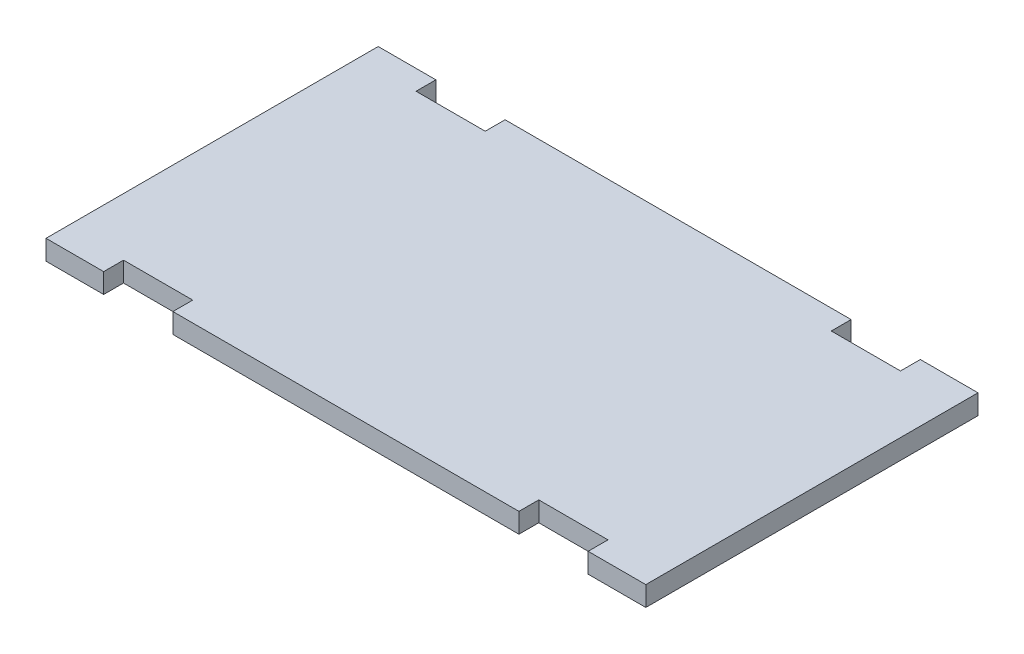
from build123d import *

# Parameters (mm, degrees)
SKETCH1_W           = 165.1
SKETCH1_H           = 91.44
BOSS_EXTRUDE1_DEPTH = 5.461
SKETCH2_W           = 19.05
SKETCH2_H           = 5.461
CUT_EXTRUDE1_DEPTH  = 6.461
BOSS_EXTRUDE2_DEPTH = 5.461


with BuildPart() as part:
    # Sketch1 → Boss-Extrude1 (new body)
    with BuildSketch(Plane(origin=(0, 0, 0), x_dir=(1, 0, 0), z_dir=(0, 1, 0))):
        with Locations((0, -0.259)):
            Rectangle(SKETCH1_W, SKETCH1_H)
        with BuildLine():
            Line((-47.5, 40), (47.5, 40))
            ThreePointArc((47.5, 40), (52.803300859, 37.803300859), (55, 32.5))
            Line((55, 32.5), (55, -32.5))
            ThreePointArc((55, -32.5), (52.803300859, -37.803300859), (47.5, -40))
            Line((47.5, -40), (-47.5, -40))
            ThreePointArc((-47.5, -40), (-52.803300859, -37.803300859), (-55, -32.5))
            Line((-55, -32.5), (-55, 32.5))
            ThreePointArc((-55, 32.5), (-52.803300859, 37.803300859), (-47.5, 40))
        make_face(mode=Mode.SUBTRACT)
    extrude(amount=BOSS_EXTRUDE1_DEPTH)

    # Sketch2 → Cut-Extrude1 (cut, through all)
    with BuildSketch(Plane(origin=(0, 5.461, 0), x_dir=(1, 0, 0), z_dir=(0, 1, 0))):
        with Locations((-57.15, 42.7305)):
            Rectangle(SKETCH2_W, SKETCH2_H)
        with Locations((-57.15, -43.2485)):
            Rectangle(SKETCH2_W, SKETCH2_H)
        with Locations((57.15, -43.2485)):
            Rectangle(SKETCH2_W, SKETCH2_H)
        with Locations((57.15, 42.7305)):
            Rectangle(SKETCH2_W, SKETCH2_H)
    extrude(amount=-CUT_EXTRUDE1_DEPTH, mode=Mode.SUBTRACT)

    # Sketch1_3 → Boss-Extrude2 (add)
    with BuildSketch(Plane(origin=(0, 0, 0), x_dir=(1, 0, 0), z_dir=(0, 1, 0))):
        with BuildLine():
            Line((-47.5, 40), (47.5, 40))
            ThreePointArc((47.5, 40), (52.803300859, 37.803300859), (55, 32.5))
            Line((55, 32.5), (55, -32.5))
            ThreePointArc((55, -32.5), (52.803300859, -37.803300859), (47.5, -40))
            Line((47.5, -40), (-47.5, -40))
            ThreePointArc((-47.5, -40), (-52.803300859, -37.803300859), (-55, -32.5))
            Line((-55, -32.5), (-55, 32.5))
            ThreePointArc((-55, 32.5), (-52.803300859, 37.803300859), (-47.5, 40))
        make_face()
    extrude(amount=BOSS_EXTRUDE2_DEPTH)


solid = part.part
